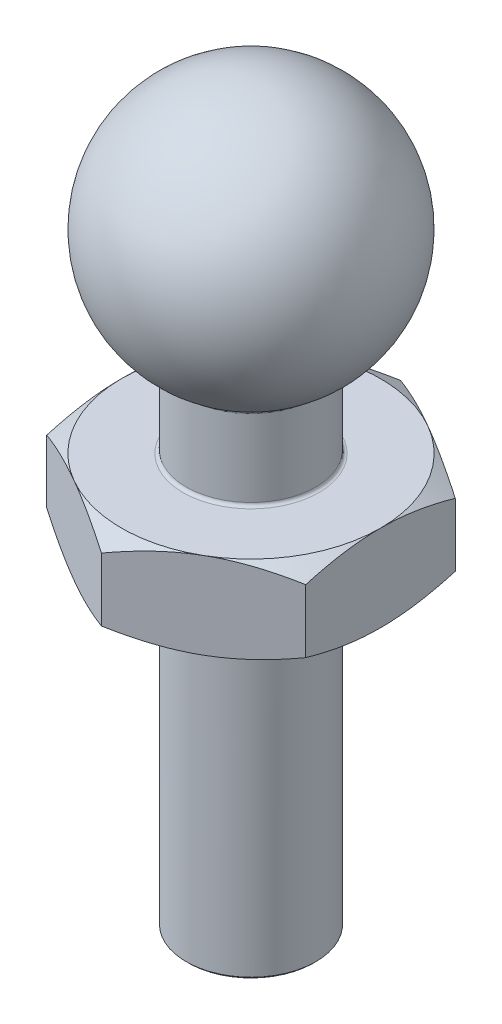
from build123d import *

# Parameters (mm, degrees)
CHAMFER1_SIZE       = 0.05
SKETCH3_R           = 1.5
BOSS_EXTRUDE1_DEPTH = 2
SKETCH4_OUTSIDE_W   = 18.79
SKETCH4_OUTSIDE_H   = 19.718
SKETCH4_OUTSIDE_R   = 3
CUT_EXTRUDE1_DEPTH  = 2
CUT_EXTRUDE1_TAPER  = 60
SKETCH6_OUTSIDE_W   = 18.79
SKETCH6_OUTSIDE_H   = 19.718
SKETCH6_OUTSIDE_R   = 3
CUT_EXTRUDE2_DEPTH  = 2
CUT_EXTRUDE2_TAPER  = 60
FILLET1_R           = 0.075


with BuildPart() as part:
    # Sketch1 → Revolve1 (revolve)
    with BuildSketch(Plane.XY):
        with BuildLine():
            Line((0, 0), (1.5, 0))
            Line((1.5, 0), (1.5, 11.401923789))
            ThreePointArc((1.5, 11.401923789), (2.897777479, 14.776457135), (0, 17))
            Line((0, 17), (0, 11))
            Line((0, 11), (0, 0))
        make_face()
    revolve(axis=Axis((0, 11, 0), (0, 1, 0)))

    # Chamfer1
    chamfer1_edges = [part.edges().sort_by_distance(p)[0] for p in [
        (-1.5, 0, 0),
    ]]
    chamfer(chamfer1_edges, length=CHAMFER1_SIZE)

    # Sketch3 → Boss-Extrude1 (add)
    with BuildSketch(Plane(origin=(0, 7.5, 0), x_dir=(1, 0, 0), z_dir=(0, 1, 0))):
        Polygon((-3, -1.732050808), (0, -3.464101615), (3, -1.732050808), (3, 1.732050808), (0, 3.464101615), (-3, 1.732050808), align=None)
        Circle(SKETCH3_R, mode=Mode.SUBTRACT)
    extrude(amount=BOSS_EXTRUDE1_DEPTH)

    # Sketch4 outside → Cut-Extrude1 (cut)
    with BuildSketch(Plane.XZ.offset(-7.5)):
        Rectangle(SKETCH4_OUTSIDE_W, SKETCH4_OUTSIDE_H)
        Circle(SKETCH4_OUTSIDE_R, mode=Mode.SUBTRACT)
    extrude(amount=-CUT_EXTRUDE1_DEPTH, taper=CUT_EXTRUDE1_TAPER, mode=Mode.SUBTRACT)

    # Sketch6 outside → Cut-Extrude2 (cut)
    with BuildSketch(Plane(origin=(0, 9.5, 0), x_dir=(1, 0, 0), z_dir=(0, 1, 0))):
        Rectangle(SKETCH6_OUTSIDE_W, SKETCH6_OUTSIDE_H)
        Circle(SKETCH6_OUTSIDE_R, mode=Mode.SUBTRACT)
    extrude(amount=-CUT_EXTRUDE2_DEPTH, taper=CUT_EXTRUDE2_TAPER, mode=Mode.SUBTRACT)

    # Fillet1
    fillet1_edges = [part.edges().sort_by_distance(p)[0] for p in [
        (-1.5, 9.5, 0),
        (-1.5, 11.401923789, 0),
    ]]
    fillet(fillet1_edges, radius=FILLET1_R)


solid = part.part
